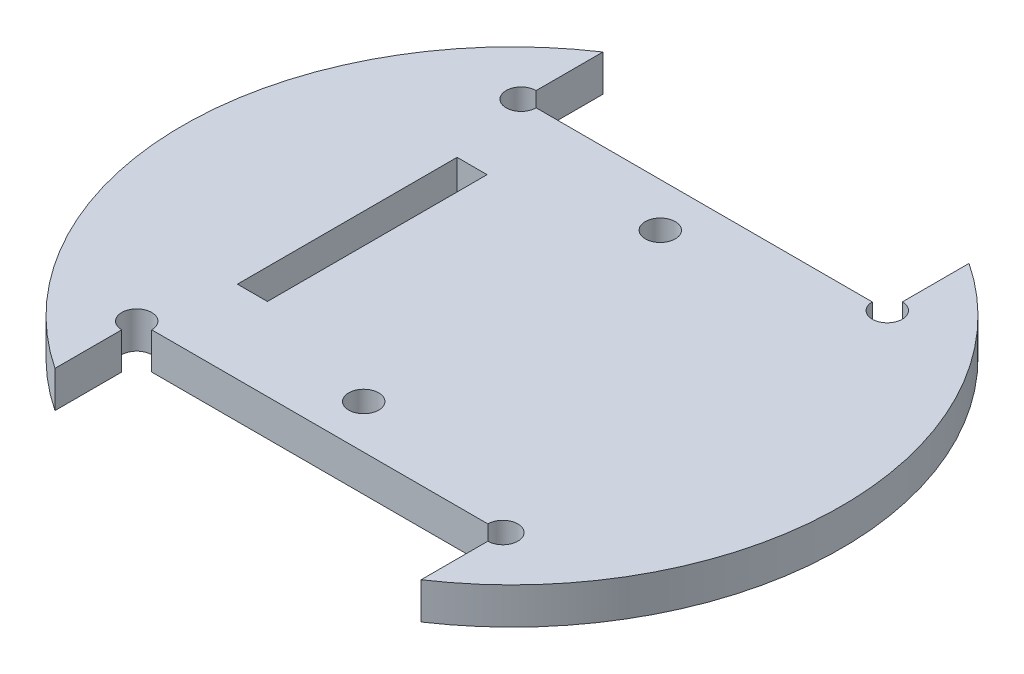
from build123d import *

# Parameters (mm, degrees)
ESTRUSIONE_ESTRUSIONE1_DEPTH = 2.5
CROQUIS2_R                   = 2.05
CORTAR_EXTRUIR1_DEPTH        = 6
CUT_EXTRUDE1_REACH           = 7
SKETCH1_W                    = 4.1
SKETCH1_H                    = 30
CUT_EXTRUDE2_REACH           = 7
SKETCH2_R                    = 2.05


with BuildPart() as part:
    # Schizzo1 → Estrusione-Estrusione1 (new body, symmetric)
    with BuildSketch(Plane(origin=(0, 0, 0), x_dir=(1, 0, 0), z_dir=(0, 1, 0))):
        with BuildLine():
            Line((-25, 37.416573868), (-25, 26.25))
            Line((-25, 26.25), (25, 26.25))
            Line((25, 26.25), (25, 37.416573868))
            ThreePointArc((25, 37.416573868), (45, 0), (25, -37.416573868))
            Line((25, -37.416573868), (25, -26.25))
            Line((25, -26.25), (-25, -26.25))
            Line((-25, -26.25), (-25, -37.416573868))
            ThreePointArc((-25, -37.416573868), (-45, 0), (-25, 37.416573868))
        make_face()
    extrude(amount=ESTRUSIONE_ESTRUSIONE1_DEPTH, both=True)

    # Croquis2 → Cortar-Extruir1 (cut, through all)
    with BuildSketch(Plane(origin=(0, 2.5, 0), x_dir=(1, 0, 0), z_dir=(0, 1, 0))):
        with Locations((0, 20.25)):
            Circle(CROQUIS2_R)
        with Locations((0, -20.25)):
            Circle(CROQUIS2_R)
    extrude(amount=-CORTAR_EXTRUIR1_DEPTH, mode=Mode.SUBTRACT)

    # Sketch1 → Cut-Extrude1 (cut, up to next)
    with BuildSketch(Plane(origin=(0, 2.5, 0), x_dir=(1, 0, 0), z_dir=(0, 1, 0)), mode=Mode.PRIVATE) as cut_extrude1_sk1:
        with Locations((-20.45, 0)):
            Rectangle(SKETCH1_W, SKETCH1_H)
    cut_extrude1_tool1 = extrude(cut_extrude1_sk1.sketch, amount=-CUT_EXTRUDE1_REACH, mode=Mode.PRIVATE) & part.part
    add(cut_extrude1_tool1.solids().sort_by_distance((-20.45, 2.5, 0))[0], mode=Mode.SUBTRACT)

    # Sketch2 → Cut-Extrude2 (cut, up to next)
    with BuildSketch(Plane(origin=(0, 2.5, 0), x_dir=(1, 0, 0), z_dir=(0, 1, 0)), mode=Mode.PRIVATE) as cut_extrude2_sk1:
        with Locations((-25, 26.25)):
            Circle(SKETCH2_R)
    cut_extrude2_tool1 = extrude(cut_extrude2_sk1.sketch, amount=-CUT_EXTRUDE2_REACH, mode=Mode.PRIVATE) & part.part
    add(cut_extrude2_tool1.solids().sort_by_distance((-25, 2.5, -26.25))[0], mode=Mode.SUBTRACT)
    # Sketch2 → Cut-Extrude2 (cut, up to next)
    with BuildSketch(Plane(origin=(0, 2.5, 0), x_dir=(1, 0, 0), z_dir=(0, 1, 0)), mode=Mode.PRIVATE) as cut_extrude2_sk2:
        with Locations((-25, -26.25)):
            Circle(SKETCH2_R)
    cut_extrude2_tool2 = extrude(cut_extrude2_sk2.sketch, amount=-CUT_EXTRUDE2_REACH, mode=Mode.PRIVATE) & part.part
    add(cut_extrude2_tool2.solids().sort_by_distance((-25, 2.5, 26.25))[0], mode=Mode.SUBTRACT)
    # Sketch2 → Cut-Extrude2 (cut, up to next)
    with BuildSketch(Plane(origin=(0, 2.5, 0), x_dir=(1, 0, 0), z_dir=(0, 1, 0)), mode=Mode.PRIVATE) as cut_extrude2_sk3:
        with Locations((25, -26.25)):
            Circle(SKETCH2_R)
    cut_extrude2_tool3 = extrude(cut_extrude2_sk3.sketch, amount=-CUT_EXTRUDE2_REACH, mode=Mode.PRIVATE) & part.part
    add(cut_extrude2_tool3.solids().sort_by_distance((25, 2.5, 26.25))[0], mode=Mode.SUBTRACT)
    # Sketch2 → Cut-Extrude2 (cut, up to next)
    with BuildSketch(Plane(origin=(0, 2.5, 0), x_dir=(1, 0, 0), z_dir=(0, 1, 0)), mode=Mode.PRIVATE) as cut_extrude2_sk4:
        with Locations((25, 26.25)):
            Circle(SKETCH2_R)
    cut_extrude2_tool4 = extrude(cut_extrude2_sk4.sketch, amount=-CUT_EXTRUDE2_REACH, mode=Mode.PRIVATE) & part.part
    add(cut_extrude2_tool4.solids().sort_by_distance((25, 2.5, -26.25))[0], mode=Mode.SUBTRACT)


solid = part.part
